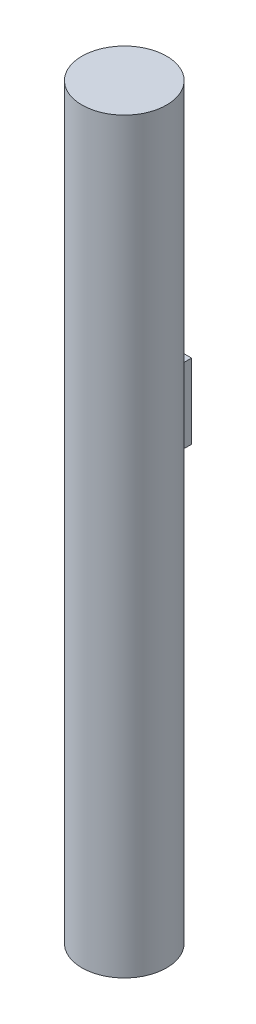
from build123d import *

# Parameters (mm, degrees)
SKETCH1_R           = 8.5
BOSS_EXTRUDE1_DEPTH = 150
SKETCH5_W           = 4
SKETCH5_H           = 11.5
BOSS_EXTRUDE2_DEPTH = 15
FILLET1_R           = 1.5


with BuildPart() as part:
    # Sketch1 → Boss-Extrude1 (new body)
    with BuildSketch(Plane(origin=(0, 0, 0), x_dir=(1, 0, 0), z_dir=(0, 1, 0))):
        Circle(SKETCH1_R)
    extrude(amount=BOSS_EXTRUDE1_DEPTH)

    # Sketch5 → Boss-Extrude2 (add)
    with BuildSketch(Plane(origin=(0, 82.02, 0), x_dir=(1, 0, 0), z_dir=(0, 1, 0))):
        with Locations((0, 5.75)):
            Rectangle(SKETCH5_W, SKETCH5_H)
    extrude(amount=BOSS_EXTRUDE2_DEPTH)

    # Fillet1
    fillet1_edges = [part.edges().sort_by_distance(p)[0] for p in [
        (0, 82.02, -8.5),
        (-2, 89.52, -8.261355821),
        (2, 89.52, -8.261355821),
        (0, 97.02, -8.5),
    ]]
    fillet(fillet1_edges, radius=FILLET1_R)


solid = part.part
